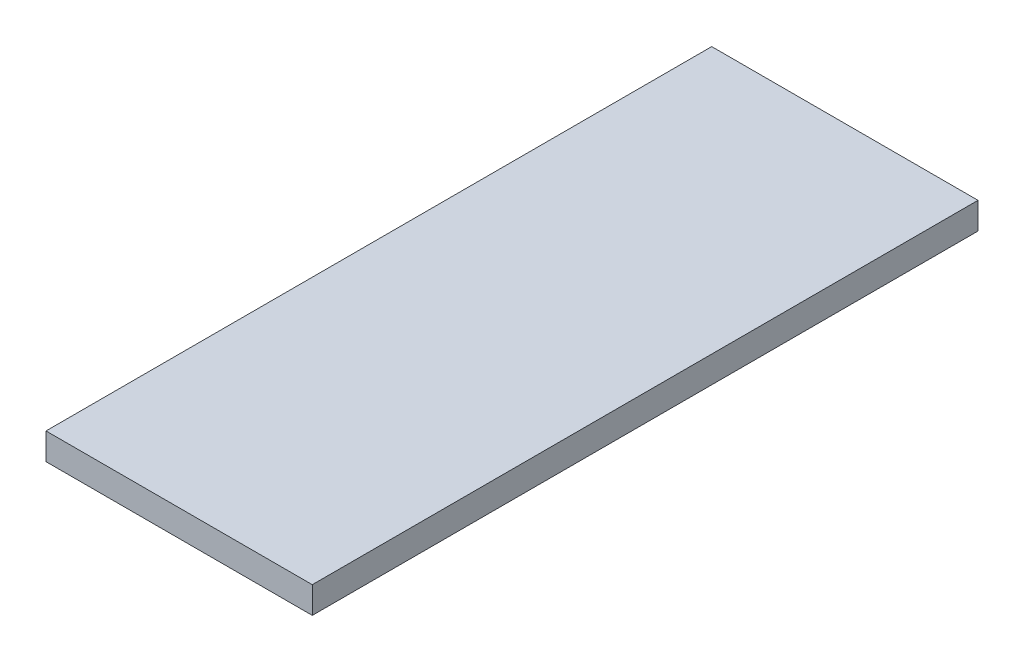
from build123d import *

# Parameters (mm, degrees)
SKETCH1_W           = 40
SKETCH1_H           = 100
BOSS_EXTRUDE1_DEPTH = 4


with BuildPart() as part:
    # Sketch1 → Boss-Extrude1 (new body)
    with BuildSketch(Plane(origin=(0, 0, 0), x_dir=(1, 0, 0), z_dir=(0, 1, 0))):
        with Locations((20, -50)):
            Rectangle(SKETCH1_W, SKETCH1_H)
    extrude(amount=BOSS_EXTRUDE1_DEPTH)


solid = part.part
